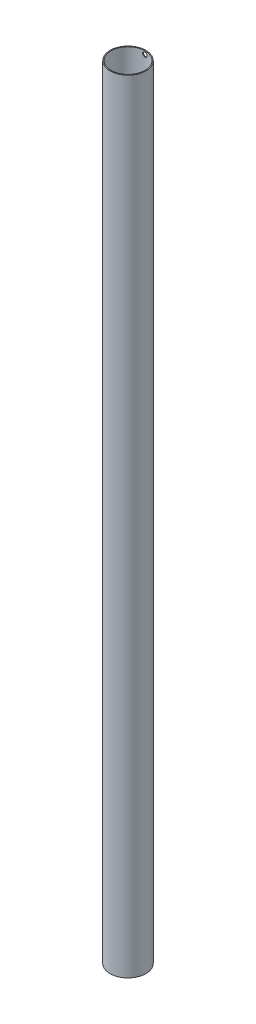
from build123d import *

# Parameters (mm, degrees)
ESQUISSE1_R             = 40
ESQUISSE1_R_2           = 38
BOSS_EXTRU_1_DEPTH      = 1750
ESQUISSE5_R             = 5
ENL_V_MAT_EXTRU_1_DEPTH = 41


with BuildPart() as part:
    # Esquisse1 → Boss.-Extru.1 (new body)
    with BuildSketch(Plane(origin=(0, 0, 0), x_dir=(1, 0, 0), z_dir=(0, 1, 0))):
        with Locations(Location((0, 0, 0), (0, 0, 270))):  # turned: the seam where the file's is
            Circle(ESQUISSE1_R)
        with Locations(Location((0, 0, 0), (0, 0, 270))):  # turned: the seam where the file's is
            Circle(ESQUISSE1_R_2, mode=Mode.SUBTRACT)
    extrude(amount=BOSS_EXTRU_1_DEPTH)

    # Esquisse5 → Enlèv. mat.-Extru.1 (cut, through all)
    with BuildSketch(Plane.XY):
        with Locations(Location((0, 1742.5, 0), (0, 0, 90))):  # turned: the seam where the file's is
            Circle(ESQUISSE5_R)
    extrude(amount=-ENL_V_MAT_EXTRU_1_DEPTH, mode=Mode.SUBTRACT)


solid = part.part
